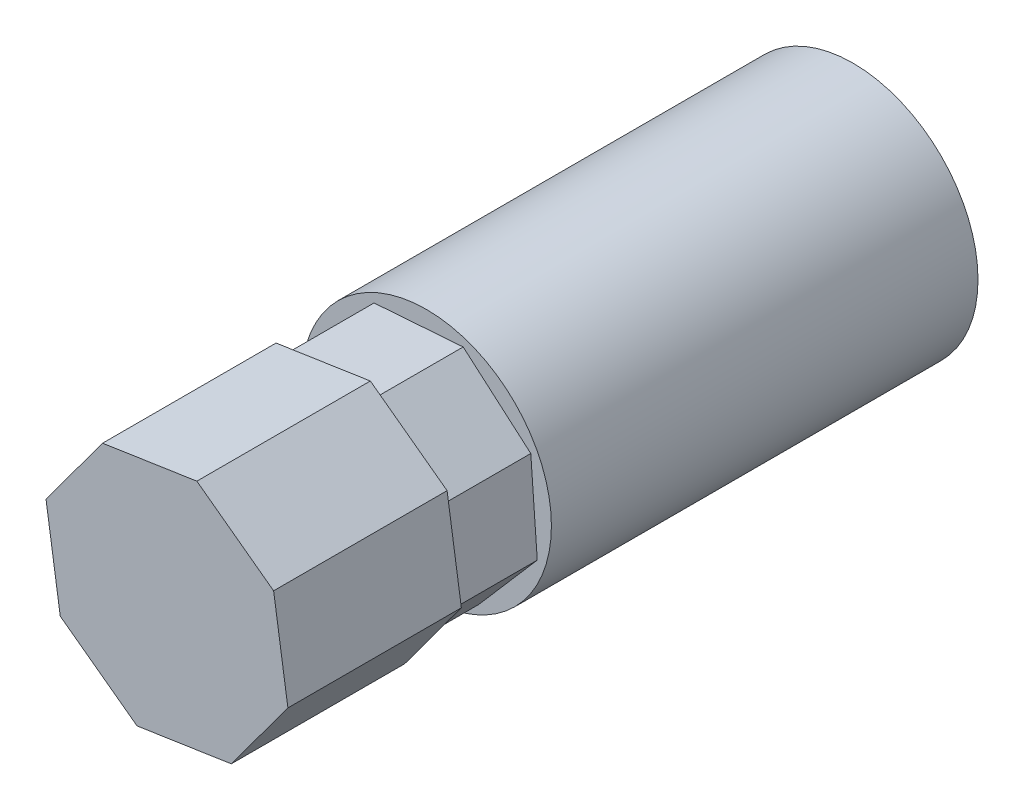
from build123d import *

# Parameters (mm, degrees)
SKETCH1_R           = 4.50215
SKETCH1_R_2         = 3.1115
BOSS_EXTRUDE2_DEPTH = 15.367
BOSS_EXTRUDE3_DEPTH = 3.0988
BOSS_EXTRUDE4_DEPTH = 6.2484


with BuildPart() as part:
    # Sketch1 → Boss-Extrude2 (new body)
    with BuildSketch(Plane.XY):
        Circle(SKETCH1_R)
        Circle(SKETCH1_R_2, mode=Mode.SUBTRACT)
    extrude(amount=BOSS_EXTRUDE2_DEPTH)

    # Sketch2 → Boss-Extrude3 (add)
    with BuildSketch(Plane.XY.offset(15.367)):
        Polygon((3.759424156, 1.886920364), (1.324060129, 3.992568499), (-1.886920364, 3.759424156), (-3.992568499, 1.324060129), (-3.759424156, -1.886920364), (-1.324060129, -3.992568499), (1.886920364, -3.759424156), (3.992568499, -1.324060129), align=None)
    extrude(amount=BOSS_EXTRUDE3_DEPTH)

    # Sketch3 → Boss-Extrude4 (add)
    with BuildSketch(Plane.XY.offset(18.4658)):
        Polygon((-2.318447564, 3.843004124), (-4.35680427, 1.078024282), (-3.843004124, -2.318447564), (-1.078024282, -4.35680427), (2.318447564, -3.843004124), (4.35680427, -1.078024282), (3.843004124, 2.318447564), (1.078024282, 4.35680427), align=None)
    extrude(amount=BOSS_EXTRUDE4_DEPTH)


solid = part.part
